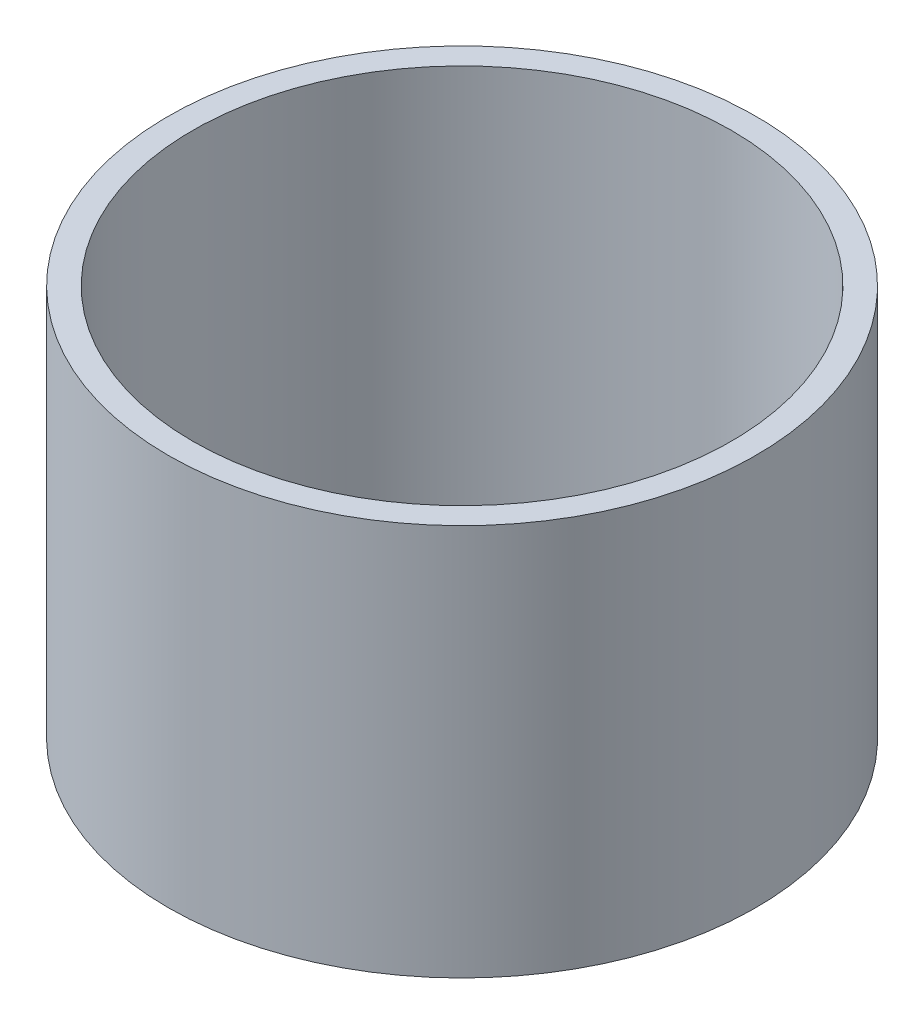
from build123d import *

# Parameters (mm, degrees)
SKETCH_1_R      = 60
SKETCH_1_R_2    = 55
EXTRUDE_1_DEPTH = 80


with BuildPart() as part:
    # 草圖1 → 填料-伸長1 (new body)
    with BuildSketch(Plane(origin=(0, 0, 0), x_dir=(1, 0, 0), z_dir=(0, 1, 0))):
        Circle(SKETCH_1_R)
        Circle(SKETCH_1_R_2, mode=Mode.SUBTRACT)
    extrude(amount=EXTRUDE_1_DEPTH)


solid = part.part
